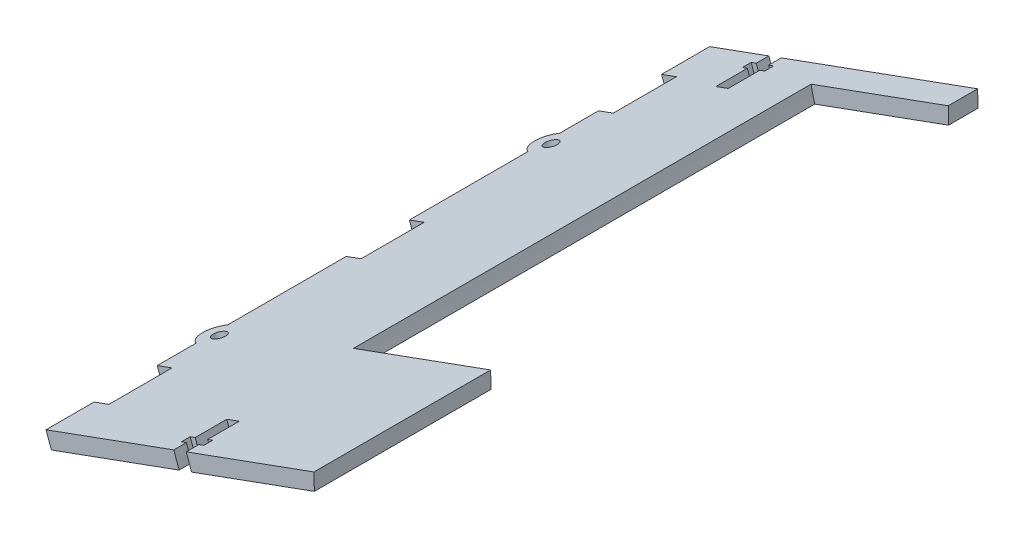
from build123d import *

# Parameters (mm, degrees)
BOSS_EXTRUDE1_DEPTH = 210.295833
SKETCH3_R           = 77.5
CUT_EXTRUDE1_DEPTH  = 145
SKETCH5_R           = 2.1
SKETCH5_W           = 5
SKETCH5_H           = 20
CUT_EXTRUDE2_DEPTH  = 5
BOSS_EXTRUDE3_DEPTH = 5


with BuildPart() as part:
    # Sketch2 → Boss-Extrude1 (new body)
    with BuildSketch(Plane.XY.offset(2)):
        Polygon((9824.878184466, 584.85282122), (9909.787083107, 615.730562883), (9909.90527281, 610.4531895), (9826.586986711, 580.153885714), align=None)
    extrude(amount=BOSS_EXTRUDE1_DEPTH)

    # Sketch3 → Cut-Extrude1 (cut)
    with BuildSketch(Plane.XY.offset(156.31)):
        with Locations((9942.206448078, 615.592583846)):
            Circle(SKETCH3_R)
    extrude(amount=-CUT_EXTRUDE1_DEPTH, mode=Mode.SUBTRACT)

    # Sketch5 → Cut-Extrude2 (cut)
    with BuildSketch(Plane(origin=(959.703546547, -2639.032739095, 0), x_dir=(0.939787101, 0.341760449, 0), z_dir=(-0.341760449, 0.939787101, 0))):
        with Locations((9435.67335083, -159.721874806)):
            Circle(SKETCH5_R)
        with Locations((9435.67335083, -54.573958269)):
            Circle(SKETCH5_R)
        Polygon((9480.447890116, -212.295833075), (9476.247890116, -212.295833075), (9476.247890116, -208.295833075), (9474.547890116, -208.295833075), (9474.547890116, -205.495833075), (9476.247890116, -205.495833075), (9476.247890116, -195.495833075), (9480.447890116, -195.495833075), (9480.447890116, -205.495833075), (9482.147890116, -205.495833075), (9482.147890116, -208.295833075), (9480.447890116, -208.295833075), align=None)
        with Locations((9435.67335083, -187.058853941)):
            Rectangle(SKETCH5_W, SKETCH5_H)
        with Locations((9435.67335083, -107.147916538)):
            Rectangle(SKETCH5_W, SKETCH5_H)
        with Locations((9435.67335083, -27.236979134)):
            Rectangle(SKETCH5_W, SKETCH5_H)
        Polygon((9453.115424439, -2), (9457.315424439, -2), (9457.315424439, -6), (9459.015424439, -6), (9459.015424439, -8.8), (9457.315424439, -8.8), (9457.315424439, -18.8), (9453.115424439, -18.8), (9453.115424439, -8.8), (9451.415424439, -8.8), (9451.415424439, -6), (9453.115424439, -6), align=None)
    extrude(amount=-CUT_EXTRUDE2_DEPTH, mode=Mode.SUBTRACT)

    # Sketch7 → Boss-Extrude3 (add)
    with BuildSketch(Plane(origin=(959.703546547, -2639.032739095, 0), x_dir=(0.939787101, 0.341760449, 0), z_dir=(-0.341760449, 0.939787101, 0))):
        with BuildLine():
            Line((9433.17335083, -49.573958269), (9433.17335083, -59.573958269))
            ThreePointArc((9433.17335083, -59.573958269), (9430.083180886, -54.573958269), (9433.17335083, -49.573958269))
        make_face()
        with BuildLine():
            Line((9433.17335083, -154.721874806), (9433.17335083, -164.721874806))
            ThreePointArc((9433.17335083, -164.721874806), (9430.083180886, -159.721874806), (9433.17335083, -154.721874806))
        make_face()
    extrude(amount=-BOSS_EXTRUDE3_DEPTH)


solid = part.part
